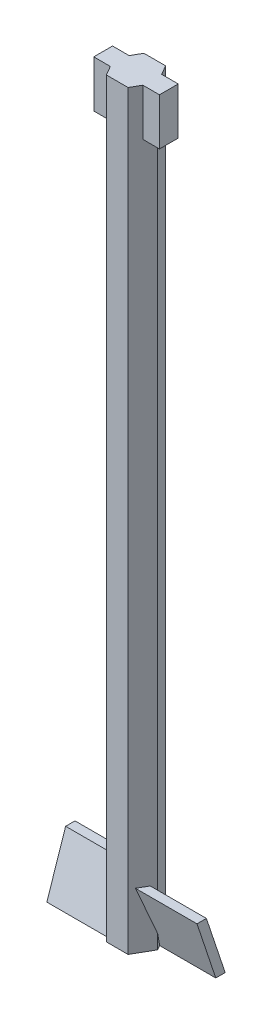
from build123d import *

# Parameters (mm, degrees)
BOSS_EXTRUDE1_DEPTH = 80
SKETCH2_W           = 7
SKETCH2_H           = 2
BOSS_EXTRUDE2_DEPTH = 5
BOSS_EXTRUDE3_DEPTH = 8
BOSS_EXTRUDE4_DEPTH = 8


with BuildPart() as part:
    # Sketch1 → Boss-Extrude1 (new body)
    with BuildSketch(Plane(origin=(0, 0, 0), x_dir=(1, 0, 0), z_dir=(0, 1, 0))):
        Polygon((-1.154700538, 2), (-2.309401077, 0), (-1.154700538, -2), (1.154700538, -2), (2.309401077, 0), (1.154700538, 2), align=None)
    extrude(amount=BOSS_EXTRUDE1_DEPTH)

    # Sketch2 → Boss-Extrude2 (add)
    with BuildSketch(Plane(origin=(0, 80, 0), x_dir=(1, 0, 0), z_dir=(0, 1, 0))):
        Rectangle(SKETCH2_W, SKETCH2_H)
    extrude(amount=-BOSS_EXTRUDE2_DEPTH)

    # Sketch3 → Boss-Extrude3 (add)
    with BuildSketch(Plane(origin=(0, 0, 0), x_dir=(0, 0, -1), z_dir=(1, 0, 0))):
        Polygon((-1.5, 6), (-0.5, 6), (1.5, 0), (0.5, 0), align=None)
    extrude(amount=BOSS_EXTRUDE3_DEPTH)

    # Sketch4 → Boss-Extrude4 (add)
    with BuildSketch(Plane(origin=(0, 0, 0), x_dir=(0, 0, -1), z_dir=(1, 0, 0))):
        Polygon((1.5, 6), (0.5, 6), (-1.5, 0), (-0.5, 0), align=None)
    extrude(amount=-BOSS_EXTRUDE4_DEPTH)


solid = part.part
